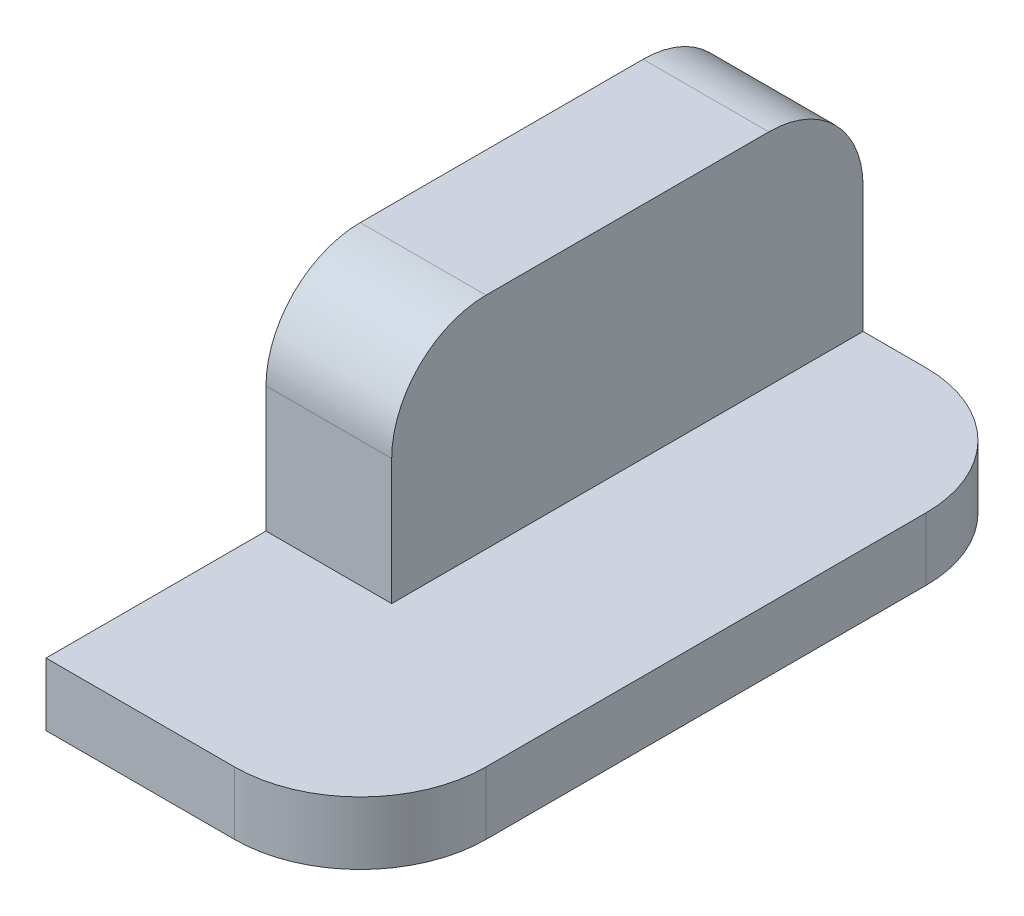
from build123d import *

# Parameters (mm, degrees)
EXTRUDE_1_DEPTH     = 50
SKETCH_2_W          = 30
SKETCH_2_H          = 35
CUT_EXTRUDE_1_DEPTH = 116
FILLET_1_R          = 15
FILLET_2_R          = 20


with BuildPart() as part:
    # 스케치1 → 보스-돌출1 (new body)
    with BuildSketch(Plane(origin=(0, 0, 0), x_dir=(0, 0, -1), z_dir=(1, 0, 0))):
        Polygon((0, 0), (35, 0), (35, 35), (110, 35), (110, -10), (0, -10), align=None)
    extrude(amount=EXTRUDE_1_DEPTH)

    # 스케치2 → 컷-돌출1 (cut)
    with BuildSketch(Plane.XY.offset(-35)):
        with Locations((35, 17.5)):
            Rectangle(SKETCH_2_W, SKETCH_2_H)
    extrude(amount=-CUT_EXTRUDE_1_DEPTH, mode=Mode.SUBTRACT)

    # 필렛1
    fillet_1_edges = [part.edges().sort_by_distance(p)[0] for p in [
        (10, 35, -35),
        (10, 35, -110),
    ]]
    fillet(fillet_1_edges, radius=FILLET_1_R)

    # 필렛2
    fillet_2_edges = [part.edges().sort_by_distance(p)[0] for p in [
        (50, -5, -110),
        (50, -5, 0),
    ]]
    fillet(fillet_2_edges, radius=FILLET_2_R)


solid = part.part
